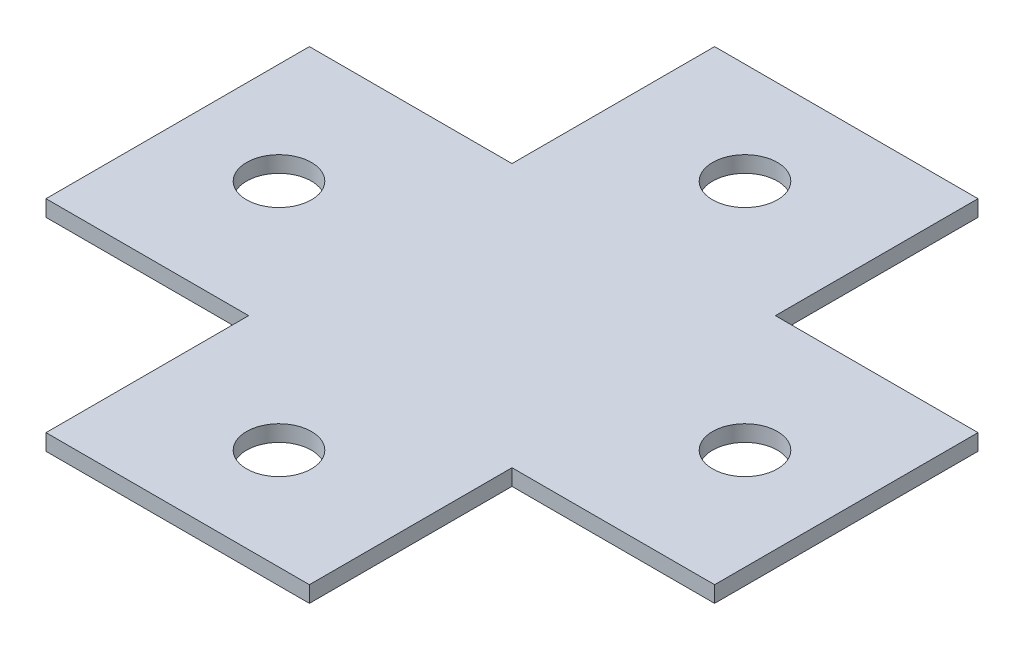
from build123d import *

# Parameters (mm, degrees)
SKETCH1_W           = 31.75
SKETCH1_H           = 41.275
SKETCH1_W_2         = 41.275
SKETCH1_H_2         = 31.75
BOSS_EXTRUDE1_DEPTH = 2.54
SKETCH2_R           = 5.08
CUT_EXTRUDE1_DEPTH  = 2.54


with BuildPart() as part:
    # Sketch1 → Boss-Extrude1 (new body)
    with BuildSketch(Plane(origin=(0, 0, 0), x_dir=(1, 0, 0), z_dir=(0, 1, 0))):
        with Locations((-36.5125, 0)):
            Rectangle(SKETCH1_W, SKETCH1_H)
        Rectangle(SKETCH1_W_2, SKETCH1_H)
        with Locations((0, -36.5125)):
            Rectangle(SKETCH1_W_2, SKETCH1_H_2)
        with Locations((0, 36.5125)):
            Rectangle(SKETCH1_W_2, SKETCH1_H_2)
        with Locations((36.5125, 0)):
            Rectangle(SKETCH1_W, SKETCH1_H)
    extrude(amount=BOSS_EXTRUDE1_DEPTH)

    # Sketch2 → Cut-Extrude1 (cut)
    with BuildSketch(Plane(origin=(0, 2.54, 0), x_dir=(1, 0, 0), z_dir=(0, 1, 0))):
        with Locations((0, -36.5125)):
            Circle(SKETCH2_R)
        with Locations((-36.5125, 0)):
            Circle(SKETCH2_R)
        with Locations((0, 36.5125)):
            Circle(SKETCH2_R)
        with Locations((36.5125, 0)):
            Circle(SKETCH2_R)
    extrude(amount=-CUT_EXTRUDE1_DEPTH, mode=Mode.SUBTRACT)


solid = part.part
